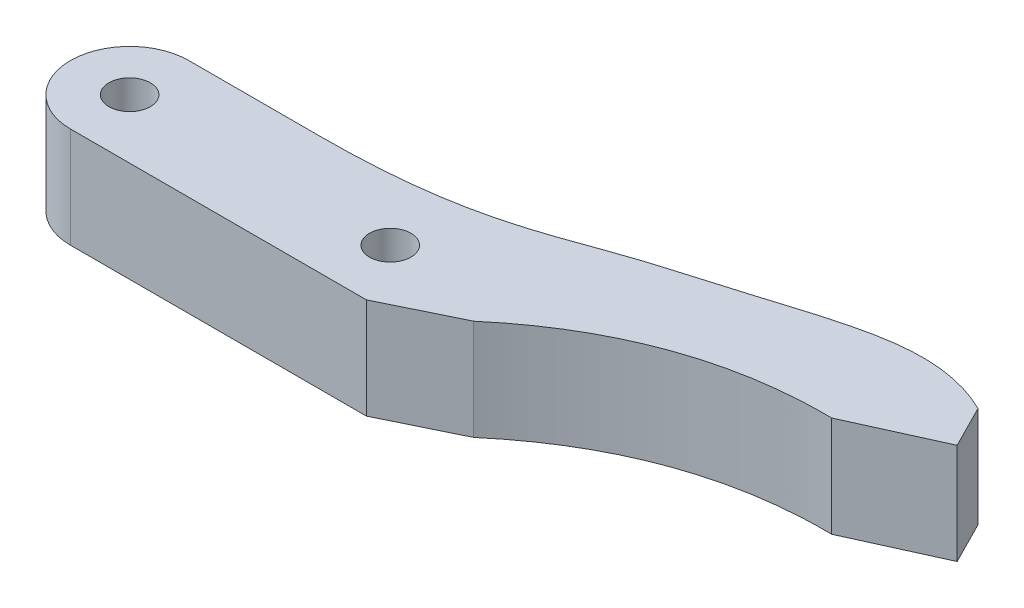
from build123d import *

# Parameters (mm, degrees)
SKETCH2_R           = 5
SKETCH2_R_2         = 1.75
BOSS_EXTRUDE1_DEPTH = 8.5
BOSS_EXTRUDE2_DEPTH = 8.5


with BuildPart() as part:
    # Sketch2 → Boss-Extrude1 (new body)
    with BuildSketch(Plane(origin=(0, 0, 0), x_dir=(1, 0, 0), z_dir=(0, 1, 0))):
        with BuildLine():
            ThreePointArc((22, -5), (17, 0), (22, 5))
            Line((22, 5), (2e-09, 5))
            ThreePointArc((2e-09, 5), (3.535533907, 3.535533905), (5, 0))
            ThreePointArc((5, 0), (3.535533908, -3.535533904), (7e-09, -5))
            Line((7e-09, -5), (22, -5))
        make_face()
        Circle(SKETCH2_R)
        Circle(SKETCH2_R_2, mode=Mode.SUBTRACT)
        with Locations((22, 0)):
            Circle(SKETCH2_R)
        with Locations((22, 0)):
            Circle(SKETCH2_R_2, mode=Mode.SUBTRACT)
    extrude(amount=BOSS_EXTRUDE1_DEPTH)

    # Sketch3 → Boss-Extrude2 (add)
    with BuildSketch(Plane(origin=(0, 8.5, 0), x_dir=(1, 0, 0), z_dir=(0, 1, 0))):
        with BuildLine():
            Line((22, -5), (24.99, -5))
            Line((24.99, -5), (31.08, -2.029708536))
            add(Edge.make_bspline(
                [(31.08, -2.029708536), (40.738723452, 6.188270814), (53.27, 6)],
                knots=[0, 0, 0, 1, 1, 1], degree=2))
            Line((53.27, 6), (60.557013712, 9.301428655))
            Line((60.557013712, 9.301428655), (58.75, 12.87))
            add(Edge.make_bspline(
                [(11, 5), (23.320985194, 5), (28.960367737, 8.21999158), (46.060199439, 12.976683932), (52.533262276, 15.918311154), (58.75, 12.87)],
                knots=[0, 0, 0, 0, 0.362024874, 0.462024874, 1, 1, 1, 1], degree=3))
            Line((11, 5), (22, 5))
            ThreePointArc((22, 5), (27, 0), (22, -5))
        make_face()
    extrude(amount=-BOSS_EXTRUDE2_DEPTH)


solid = part.part
